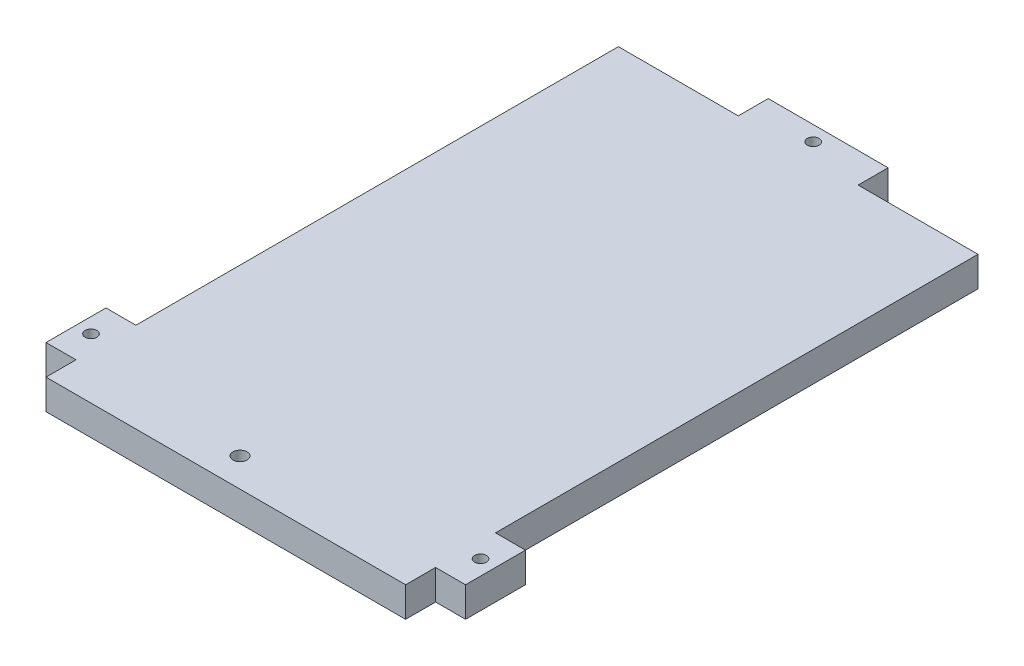
from build123d import *

# Parameters (mm, degrees)
BOSS_EXTRUDE1_DEPTH = 6.35
SKETCH2_R           = 1.5
CUT_EXTRUDE1_DEPTH  = 7.35
SKETCH3_R           = 1.25
CUT_EXTRUDE2_DEPTH  = 7.35


with BuildPart() as part:
    # Sketch1 → Boss-Extrude1 (new body)
    with BuildSketch(Plane(origin=(0, 0, 0), x_dir=(1, 0, 0), z_dir=(0, 1, 0))):
        Polygon((50.8, 121.285), (76.2, 121.285), (76.2, 19.05), (82.55, 19.05), (82.55, 6.35), (76.2, 6.35), (76.2, 0), (0, 0), (0, 6.35), (-6.35, 6.35), (-6.35, 19.05), (0, 19.05), (0, 121.285), (25.4, 121.285), (25.4, 127.635), (50.8, 127.635), align=None)
    extrude(amount=BOSS_EXTRUDE1_DEPTH)

    # Sketch2 → Cut-Extrude1 (cut, through all)
    with BuildSketch(Plane(origin=(0, 6.35, 0), x_dir=(1, 0, 0), z_dir=(0, 1, 0))):
        with Locations((35.0139, 6.096)):
            Circle(SKETCH2_R)
    extrude(amount=-CUT_EXTRUDE1_DEPTH, mode=Mode.SUBTRACT)

    # Sketch3 → Cut-Extrude2 (cut, through all)
    with BuildSketch(Plane(origin=(0, 6.35, 0), x_dir=(1, 0, 0), z_dir=(0, 1, 0))):
        with Locations((-3.175, 12.7)):
            Circle(SKETCH3_R)
        with Locations((79.375, 12.7)):
            Circle(SKETCH3_R)
        with Locations((38.1, 124.46)):
            Circle(SKETCH3_R)
    extrude(amount=-CUT_EXTRUDE2_DEPTH, mode=Mode.SUBTRACT)


solid = part.part
